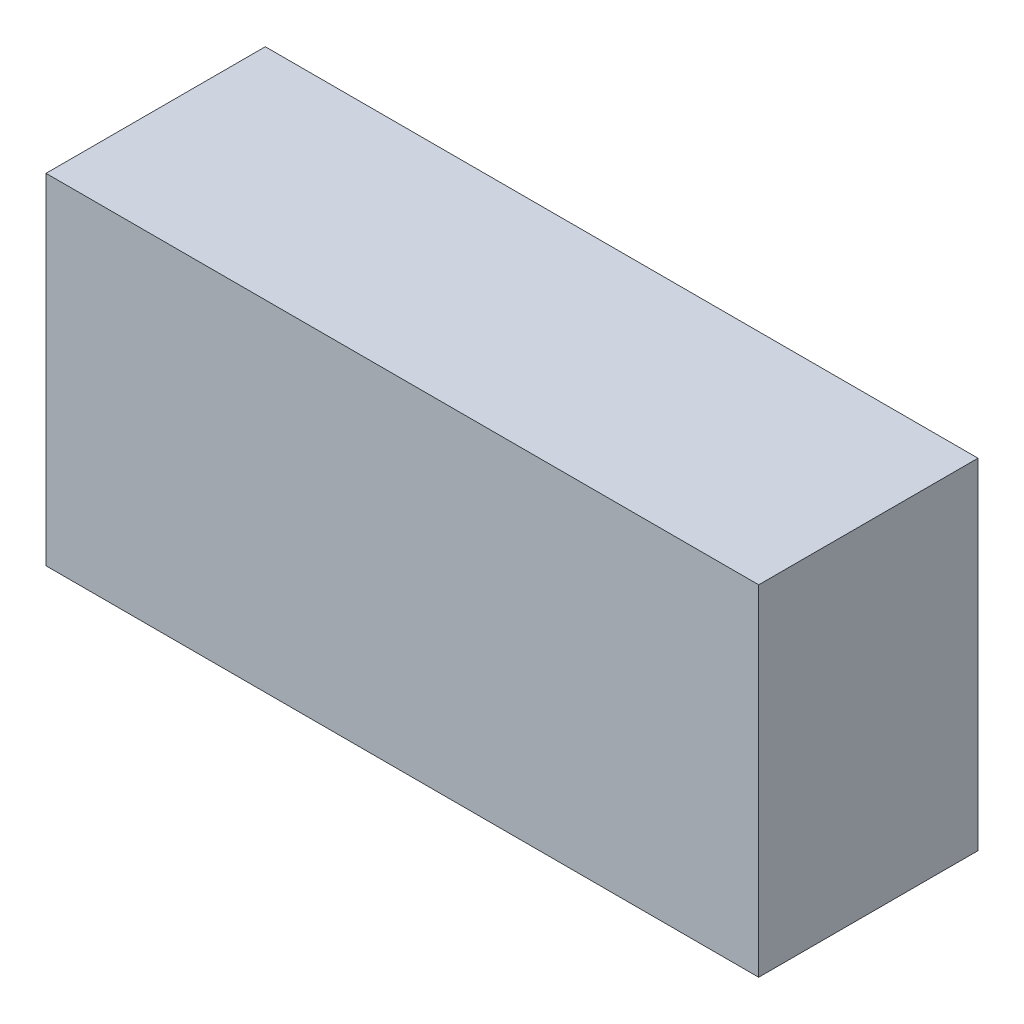
from build123d import *

# Parameters (mm, degrees)
SKETCH_1_W      = 19.5
SKETCH_1_H      = 6
EXTRUDE_1_DEPTH = 9.3
SKETCH_2_W      = 0.6
SKETCH_2_H      = 0.3
EXTRUDE_2_DEPTH = 3
EXTRUDE_3_DEPTH = 0.2


with BuildPart() as part:
    # Эскиз1 → Бобышка-Вытянуть1 (new body)
    with BuildSketch(Plane(origin=(0, 0, 0), x_dir=(1, 0, 0), z_dir=(0, 1, 0))):
        Rectangle(SKETCH_1_W, SKETCH_1_H)
    extrude(amount=EXTRUDE_1_DEPTH)

    # Эскиз2 → Бобышка-Вытянуть2 (add)
    with BuildSketch(Plane.XZ):
        with Locations((-7.62, -1.35)):
            Rectangle(SKETCH_2_W, SKETCH_2_H)
        with Locations((-5.08, -1.35)):
            Rectangle(SKETCH_2_W, SKETCH_2_H)
        with Locations((0, -1.35)):
            Rectangle(SKETCH_2_W, SKETCH_2_H)
        with Locations((2.54, -1.35)):
            Rectangle(SKETCH_2_W, SKETCH_2_H)
        with Locations((5.08, -1.35)):
            Rectangle(SKETCH_2_W, SKETCH_2_H)
    extrude(amount=EXTRUDE_2_DEPTH)

    # Эскиз3 → Бобышка-Вытянуть3 (add)
    with BuildSketch(Plane(origin=(0, 9.3, 0), x_dir=(1, 0, 0), z_dir=(0, 1, 0))):
        with BuildLine():
            Line((-5.993653669, -1.1506083), (-5.993653669, 1.495225034))
            Line((-5.993653669, 1.495225034), (-5.726526265, 1.495225034))
            add(Edge.make_bspline(
                [(-5.726526265, 1.495225034), (-5.703199399, 1.494894605), (-5.65827213, 1.494258204), (-5.593328368, 1.490121291), (-5.533294043, 1.482863062), (-5.478257825, 1.472268509), (-5.427978548, 1.459234752), (-5.382722262, 1.442777118), (-5.342163377, 1.423550544), (-5.318249105, 1.407525081), (-5.30675463, 1.39982239)],
                knots=[0, 0, 0, 0, 6.998e-05, 0.000134781, 0.00019513, 0.000251262, 0.000302815, 0.000350769, 0.00039557, 0.000437033, 0.000437033, 0.000437033, 0.000437033], degree=3))
            add(Edge.make_bspline(
                [(-5.30675463, 1.39982239), (-5.291259723, 1.387980041), (-5.259666671, 1.363834307), (-5.216878942, 1.320049614), (-5.176018095, 1.270953839), (-5.138198125, 1.215037198), (-5.103093917, 1.153229673), (-5.069860634, 1.085379539), (-5.040008142, 1.011214307), (-5.012613306, 0.931196499), (-4.987736933, 0.846373762), (-4.966676113, 0.756972928), (-4.948733764, 0.663775398), (-4.933891633, 0.566532567), (-4.922334069, 0.465223791), (-4.913792213, 0.359881256), (-4.909099881, 0.250617555), (-4.908492313, 0.176552723), (-4.908183583, 0.138917442)],
                knots=[0, 0, 0, 0, 5.8439e-05, 0.000119153, 0.000183146, 0.000249888, 0.000321348, 0.000396253, 0.000476369, 0.000561014, 0.000649908, 0.00074144, 0.000836447, 0.000934568, 0.00103647, 0.001142284, 0.001251571, 0.001364475, 0.001364475, 0.001364475, 0.001364475], degree=3))
            add(Edge.make_bspline(
                [(-4.908183583, 0.138917442), (-4.908280711, 0.106227192), (-4.908471905, 0.041877192), (-4.913150802, -0.053011126), (-4.919308515, -0.144931602), (-4.928055359, -0.233911091), (-4.940620124, -0.319900369), (-4.954621979, -0.403063397), (-4.971578805, -0.483169429), (-4.991199381, -0.559859585), (-5.012673437, -0.632560972), (-5.036144523, -0.700772196), (-5.060756945, -0.763964681), (-5.08687661, -0.822459494), (-5.11469083, -0.875845291), (-5.14459931, -0.924137506), (-5.175194817, -0.968146848), (-5.208238178, -1.00695942), (-5.243405122, -1.041684613), (-5.282312993, -1.070675465), (-5.324207669, -1.095483025), (-5.369598006, -1.115586755), (-5.418401512, -1.131573487), (-5.470683253, -1.142394162), (-5.525977989, -1.149628644), (-5.56396405, -1.150276458), (-5.583422299, -1.1506083)],
                knots=[0, 0, 0, 0, 9.8058e-05, 0.000193026, 0.000284939, 0.000374436, 0.000461159, 0.000545593, 0.000627403, 0.000706717, 0.000783019, 0.000854758, 0.000923064, 0.000986404, 0.001046858, 0.001103491, 0.001156725, 0.001207487, 0.001256214, 0.001304658, 0.001352653, 0.001402001, 0.001453289, 0.00150641, 0.00156196, 0.0016203, 0.0016203, 0.0016203, 0.0016203], degree=3))
            Line((-5.583422299, -1.1506083), (-5.993653669, -1.1506083))
        make_face()
        with BuildLine():
            Line((-5.857969908, -0.879240778), (-5.712215868, -0.879240778))
            add(Edge.make_bspline(
                [(-5.712215868, -0.879240778), (-5.691187559, -0.879056917), (-5.650871591, -0.878704415), (-5.592868926, -0.875504605), (-5.539970165, -0.870356677), (-5.491975474, -0.863079212), (-5.449019914, -0.853425769), (-5.410665043, -0.842750873), (-5.377422356, -0.829210676), (-5.358215906, -0.817468128), (-5.349155806, -0.811928913)],
                knots=[0, 0, 0, 0, 6.3081e-05, 0.00012094, 0.000174206, 0.000222481, 0.000266459, 0.00030621, 0.000341843, 0.000373662, 0.000373662, 0.000373662, 0.000373662], degree=3))
            add(Edge.make_bspline(
                [(-5.349155806, -0.811928913), (-5.337504042, -0.803307558), (-5.313789347, -0.785760618), (-5.280583663, -0.754767955), (-5.250258232, -0.718316423), (-5.220506136, -0.67810954), (-5.194552767, -0.631854361), (-5.168983681, -0.581836894), (-5.145554456, -0.526783834), (-5.124665533, -0.467032902), (-5.105604787, -0.403212154), (-5.089398291, -0.335730556), (-5.074936985, -0.265071796), (-5.063189934, -0.190820741), (-5.055092671, -0.112940991), (-5.048787041, -0.03182255), (-5.044151944, 0.052648833), (-5.043963526, 0.110113423), (-5.043867344, 0.139447456)],
                knots=[0, 0, 0, 0, 4.3464e-05, 8.8463e-05, 0.000135833, 0.000185556, 0.000238281, 0.000294694, 0.000354058, 0.000417592, 0.000484502, 0.00055379, 0.00062572, 0.000700832, 0.000779205, 0.000860546, 0.000944925, 0.001032914, 0.001032914, 0.001032914, 0.001032914], degree=3))
            add(Edge.make_bspline(
                [(-5.043867344, 0.139447456), (-5.044257686, 0.170367783), (-5.045023027, 0.230993015), (-5.04851762, 0.320105791), (-5.055303295, 0.405703496), (-5.065721936, 0.487818585), (-5.0773982, 0.566813362), (-5.093024206, 0.642256147), (-5.110894459, 0.714268364), (-5.131375406, 0.782633857), (-5.154756204, 0.846351158), (-5.179273421, 0.905648959), (-5.207154577, 0.959280213), (-5.236388534, 1.0081843), (-5.26864597, 1.051395115), (-5.302252635, 1.09000415), (-5.339137971, 1.122477508), (-5.365409332, 1.140706418), (-5.378306614, 1.149655456)],
                knots=[0, 0, 0, 0, 9.2766e-05, 0.000181886, 0.000267496, 0.000350263, 0.000430171, 0.000506986, 0.000581287, 0.000652715, 0.000720955, 0.000784843, 0.000845053, 0.000902138, 0.000955564, 0.001006622, 0.001055435, 0.001102508, 0.001102508, 0.001102508, 0.001102508], degree=3))
            add(Edge.make_bspline(
                [(-5.378306614, 1.149655456), (-5.388955984, 1.155743208), (-5.411039459, 1.168367307), (-5.448391882, 1.183007997), (-5.490098558, 1.195464632), (-5.536608314, 1.206268717), (-5.588034553, 1.213841748), (-5.644095768, 1.219565094), (-5.704918011, 1.223470072), (-5.747013657, 1.223724871), (-5.76892744, 1.223857512)],
                knots=[0, 0, 0, 0, 3.6759e-05, 7.6226e-05, 0.000119987, 0.000167301, 0.000219323, 0.000275807, 0.000336342, 0.000402072, 0.000402072, 0.000402072, 0.000402072], degree=3))
            Line((-5.76892744, 1.223857512), (-5.857969908, 1.223857512))
            Line((-5.857969908, 1.223857512), (-5.857969908, -0.879240778))
        make_face(mode=Mode.SUBTRACT)
        with BuildLine():
            Line((-3.415662216, 1.009731578), (-3.519545095, 0.850727171))
            add(Edge.make_bspline(
                [(-3.519545095, 0.850727171), (-3.534179354, 0.884905992), (-3.562170932, 0.950281296), (-3.611133312, 1.040000729), (-3.665533305, 1.116106536), (-3.72384652, 1.179351808), (-3.785927203, 1.2295169), (-3.851769423, 1.265264449), (-3.920886372, 1.287938638), (-3.968476618, 1.290444177), (-3.992318199, 1.291699393)],
                knots=[0, 0, 0, 0, 0.000111505, 0.00021328, 0.000305946, 0.000391448, 0.000470663, 0.000544181, 0.000615258, 0.000686614, 0.000686614, 0.000686614, 0.000686614], degree=3))
            add(Edge.make_bspline(
                [(-3.992318199, 1.291699393), (-4.005431836, 1.291384283), (-4.03169845, 1.290753119), (-4.070396571, 1.282732829), (-4.108512905, 1.271147784), (-4.145817601, 1.254474313), (-4.182279862, 1.233158987), (-4.218304257, 1.207461497), (-4.252957775, 1.176608367), (-4.299075833, 1.128977162), (-4.352642098, 1.059690199), (-4.408114943, 0.964195578), (-4.457114694, 0.856544197), (-4.497127403, 0.73650285), (-4.529213424, 0.606387938), (-4.552370998, 0.467849217), (-4.566279092, 0.321350851), (-4.568060213, 0.221100812), (-4.568974182, 0.169658294)],
                knots=[0, 0, 0, 0, 3.9278e-05, 7.8675e-05, 0.000118071, 0.000158647, 0.000200919, 0.000244603, 0.000291171, 0.000339898, 0.000443375, 0.000552908, 0.000670553, 0.000797599, 0.000931932, 0.001072217, 0.001218621, 0.001372929, 0.001372929, 0.001372929, 0.001372929], degree=3))
            add(Edge.make_bspline(
                [(-4.568974182, 0.169658294), (-4.568505048, 0.130597956), (-4.567586992, 0.054160166), (-4.559240598, -0.057952809), (-4.546936059, -0.165048085), (-4.528789063, -0.267326934), (-4.505707102, -0.364750482), (-4.477047103, -0.45737923), (-4.443102256, -0.544809514), (-4.404897438, -0.626691155), (-4.362284373, -0.700931952), (-4.317155352, -0.766581502), (-4.268464955, -0.821815298), (-4.217519197, -0.867484278), (-4.163381985, -0.903364651), (-4.106076555, -0.928124148), (-4.046251249, -0.944766536), (-4.0051504, -0.946304829), (-3.984367978, -0.947082659)],
                knots=[0, 0, 0, 0, 0.000117163, 0.000229279, 0.000337095, 0.000440441, 0.000540713, 0.000637275, 0.000731075, 0.000821883, 0.000908068, 0.000987615, 0.00106046, 0.00112842, 0.001192368, 0.001254309, 0.001315115, 0.00137731, 0.00137731, 0.00137731, 0.00137731], degree=3))
            add(Edge.make_bspline(
                [(-3.984367978, -0.947082659), (-3.961591638, -0.945772388), (-3.91597232, -0.943148013), (-3.849479838, -0.921072886), (-3.786097826, -0.886024876), (-3.72623861, -0.836482885), (-3.669438198, -0.773568722), (-3.615488809, -0.697122197), (-3.564594685, -0.606919476), (-3.53506219, -0.540833581), (-3.519545095, -0.506110436)],
                knots=[0, 0, 0, 0, 6.8191e-05, 0.000136581, 0.000207984, 0.00028447, 0.000368503, 0.0004616, 0.000564616, 0.000678669, 0.000678669, 0.000678669, 0.000678669], degree=3))
            Line((-3.519545095, -0.506110436), (-3.415662216, -0.663524799))
            add(Edge.make_bspline(
                [(-3.415662216, -0.663524799), (-3.423957596, -0.684978718), (-3.440269776, -0.727166079), (-3.467335967, -0.787728881), (-3.495194986, -0.84501035), (-3.525867748, -0.89780762), (-3.556548419, -0.947988701), (-3.590310996, -0.993379854), (-3.624691432, -1.035567179), (-3.660650472, -1.073847065), (-3.698141543, -1.107588466), (-3.736619231, -1.137280461), (-3.77637805, -1.161955477), (-3.816885086, -1.183164813), (-3.85890478, -1.199070077), (-3.902132842, -1.210062204), (-3.946310126, -1.217400972), (-3.976211705, -1.218098955), (-3.991258169, -1.21845018)],
                knots=[0, 0, 0, 0, 6.8994e-05, 0.00013567, 0.000198958, 0.000259965, 0.000318787, 0.00037529, 0.000429512, 0.000482002, 0.000532665, 0.000580686, 0.000627598, 0.000672873, 0.000717662, 0.000762012, 0.00080654, 0.000851641, 0.000851641, 0.000851641, 0.000851641], degree=3))
            add(Edge.make_bspline(
                [(-3.991258169, -1.21845018), (-4.019498028, -1.217044905), (-4.0752501, -1.214270565), (-4.156243448, -1.191380627), (-4.232478086, -1.154894405), (-4.303933806, -1.103497233), (-4.369809131, -1.03705277), (-4.431329731, -0.956814193), (-4.488334905, -0.862118671), (-4.520381829, -0.792319622), (-4.5371733, -0.755747355)],
                knots=[0, 0, 0, 0, 8.4598e-05, 0.000167017, 0.000250464, 0.000337091, 0.000429662, 0.000530164, 0.000639786, 0.000760445, 0.000760445, 0.000760445, 0.000760445], degree=3))
            add(Edge.make_bspline(
                [(-4.5371733, -0.755747355), (-4.550705935, -0.722524172), (-4.578175766, -0.655084593), (-4.611354565, -0.549272101), (-4.641067127, -0.438918067), (-4.663731428, -0.323171427), (-4.682780542, -0.202666631), (-4.694840811, -0.076988272), (-4.7032721, 0.053646598), (-4.704190154, 0.142436449), (-4.704657942, 0.187678793)],
                knots=[0, 0, 0, 0, 0.000107577, 0.000218371, 0.000332403, 0.000450276, 0.000572011, 0.000698267, 0.000828893, 0.000964602, 0.000964602, 0.000964602, 0.000964602], degree=3))
            add(Edge.make_bspline(
                [(-4.704657942, 0.187678793), (-4.704071921, 0.235219874), (-4.702922615, 0.328457448), (-4.693182896, 0.465378871), (-4.677450347, 0.596485968), (-4.655352591, 0.721825733), (-4.626464582, 0.841351733), (-4.592607123, 0.955511927), (-4.550817993, 1.063548764), (-4.503763829, 1.164964211), (-4.452114913, 1.257588782), (-4.39660512, 1.338869898), (-4.33732567, 1.407454084), (-4.27538001, 1.464439326), (-4.209548403, 1.508797556), (-4.140164332, 1.539888447), (-4.067577761, 1.559396918), (-4.017878723, 1.561837656), (-3.992848213, 1.563066914)],
                knots=[0, 0, 0, 0, 0.000142609, 0.000279686, 0.000411561, 0.00053861, 0.00066125, 0.000780297, 0.000895559, 0.001008427, 0.001115455, 0.00121337, 0.001303168, 0.001386845, 0.001465196, 0.00154016, 0.001614078, 0.00168908, 0.00168908, 0.00168908, 0.00168908], degree=3))
            add(Edge.make_bspline(
                [(-3.992848213, 1.563066914), (-3.977627939, 1.562703678), (-3.947380615, 1.561981816), (-3.902594067, 1.554813267), (-3.859097397, 1.543179618), (-3.816832763, 1.526858437), (-3.775181493, 1.507110913), (-3.73550092, 1.4809088), (-3.696205136, 1.451551931), (-3.658548924, 1.417201519), (-3.62206409, 1.379288724), (-3.587540342, 1.337134575), (-3.554988139, 1.291302038), (-3.522540397, 1.242799461), (-3.494096057, 1.189331801), (-3.46554633, 1.133068857), (-3.43918824, 1.072902791), (-3.423587095, 1.031011171), (-3.415662216, 1.009731578)],
                knots=[0, 0, 0, 0, 4.5631e-05, 9.0682e-05, 0.00013568, 0.000180469, 0.000226455, 0.00027365, 0.000322836, 0.000373499, 0.000426354, 0.000480576, 0.000536768, 0.000594983, 0.000655472, 0.000718285, 0.000784263, 0.000852377, 0.000852377, 0.000852377, 0.000852377], degree=3))
        make_face()
        with BuildLine():
            Line((-1.448247686, 1.009731578), (-1.552130565, 0.850727171))
            add(Edge.make_bspline(
                [(-1.552130565, 0.850727171), (-1.566764824, 0.884905992), (-1.594756402, 0.950281296), (-1.643718782, 1.040000729), (-1.698118775, 1.116106536), (-1.75643199, 1.179351808), (-1.818512673, 1.2295169), (-1.884354893, 1.265264449), (-1.953471842, 1.287938638), (-2.001062088, 1.290444177), (-2.024903669, 1.291699393)],
                knots=[0, 0, 0, 0, 0.000111505, 0.00021328, 0.000305946, 0.000391448, 0.000470663, 0.000544181, 0.000615258, 0.000686614, 0.000686614, 0.000686614, 0.000686614], degree=3))
            add(Edge.make_bspline(
                [(-2.024903669, 1.291699393), (-2.038017306, 1.291384283), (-2.06428392, 1.290753119), (-2.102982041, 1.282732829), (-2.141098375, 1.271147784), (-2.178403071, 1.254474313), (-2.214865332, 1.233158987), (-2.250889728, 1.207461497), (-2.285543246, 1.176608367), (-2.331661303, 1.128977162), (-2.385227568, 1.059690199), (-2.440700413, 0.964195578), (-2.489700164, 0.856544197), (-2.529712873, 0.73650285), (-2.561798894, 0.606387938), (-2.584956468, 0.467849217), (-2.598864562, 0.321350851), (-2.600645683, 0.221100812), (-2.601559652, 0.169658294)],
                knots=[0, 0, 0, 0, 3.9278e-05, 7.8675e-05, 0.000118071, 0.000158647, 0.000200919, 0.000244603, 0.000291171, 0.000339898, 0.000443375, 0.000552908, 0.000670553, 0.000797599, 0.000931932, 0.001072217, 0.001218621, 0.001372929, 0.001372929, 0.001372929, 0.001372929], degree=3))
            add(Edge.make_bspline(
                [(-2.601559652, 0.169658294), (-2.601090518, 0.130597956), (-2.600172462, 0.054160166), (-2.591826069, -0.057952809), (-2.579521529, -0.165048085), (-2.561374533, -0.267326934), (-2.538292572, -0.364750482), (-2.509632573, -0.45737923), (-2.475687726, -0.544809514), (-2.437482908, -0.626691155), (-2.394869843, -0.700931952), (-2.349740822, -0.766581502), (-2.301050425, -0.821815298), (-2.250104667, -0.867484278), (-2.195967455, -0.903364651), (-2.138662025, -0.928124148), (-2.078836719, -0.944766536), (-2.03773587, -0.946304829), (-2.016953448, -0.947082659)],
                knots=[0, 0, 0, 0, 0.000117163, 0.000229279, 0.000337095, 0.000440441, 0.000540713, 0.000637275, 0.000731075, 0.000821883, 0.000908068, 0.000987615, 0.00106046, 0.00112842, 0.001192368, 0.001254309, 0.001315115, 0.00137731, 0.00137731, 0.00137731, 0.00137731], degree=3))
            add(Edge.make_bspline(
                [(-2.016953448, -0.947082659), (-1.994177108, -0.945772388), (-1.94855779, -0.943148013), (-1.882065308, -0.921072886), (-1.818683296, -0.886024876), (-1.75882408, -0.836482885), (-1.702023668, -0.773568722), (-1.648074279, -0.697122197), (-1.597180155, -0.606919476), (-1.56764766, -0.540833581), (-1.552130565, -0.506110436)],
                knots=[0, 0, 0, 0, 6.8191e-05, 0.000136581, 0.000207984, 0.00028447, 0.000368503, 0.0004616, 0.000564616, 0.000678669, 0.000678669, 0.000678669, 0.000678669], degree=3))
            Line((-1.552130565, -0.506110436), (-1.448247686, -0.663524799))
            add(Edge.make_bspline(
                [(-1.448247686, -0.663524799), (-1.456543066, -0.684978718), (-1.472855246, -0.727166079), (-1.499921437, -0.787728881), (-1.527780456, -0.84501035), (-1.558453218, -0.89780762), (-1.589133889, -0.947988701), (-1.622896466, -0.993379854), (-1.657276903, -1.035567179), (-1.693235942, -1.073847065), (-1.730727013, -1.107588466), (-1.769204701, -1.137280461), (-1.80896352, -1.161955477), (-1.849470556, -1.183164813), (-1.89149025, -1.199070077), (-1.934718312, -1.210062204), (-1.978895596, -1.217400972), (-2.008797175, -1.218098955), (-2.023843639, -1.21845018)],
                knots=[0, 0, 0, 0, 6.8994e-05, 0.00013567, 0.000198958, 0.000259965, 0.000318787, 0.00037529, 0.000429512, 0.000482002, 0.000532665, 0.000580686, 0.000627598, 0.000672873, 0.000717662, 0.000762012, 0.00080654, 0.000851641, 0.000851641, 0.000851641, 0.000851641], degree=3))
            add(Edge.make_bspline(
                [(-2.023843639, -1.21845018), (-2.052083499, -1.217044905), (-2.10783557, -1.214270565), (-2.188828918, -1.191380627), (-2.265063556, -1.154894405), (-2.336519276, -1.103497233), (-2.402394601, -1.03705277), (-2.463915201, -0.956814193), (-2.520920375, -0.862118671), (-2.552967299, -0.792319622), (-2.56975877, -0.755747355)],
                knots=[0, 0, 0, 0, 8.4598e-05, 0.000167017, 0.000250464, 0.000337091, 0.000429662, 0.000530164, 0.000639786, 0.000760445, 0.000760445, 0.000760445, 0.000760445], degree=3))
            add(Edge.make_bspline(
                [(-2.56975877, -0.755747355), (-2.583291406, -0.722524172), (-2.610761236, -0.655084593), (-2.643940035, -0.549272101), (-2.673652597, -0.438918067), (-2.696316898, -0.323171427), (-2.715366012, -0.202666631), (-2.727426281, -0.076988272), (-2.73585757, 0.053646598), (-2.736775624, 0.142436449), (-2.737243412, 0.187678793)],
                knots=[0, 0, 0, 0, 0.000107577, 0.000218371, 0.000332403, 0.000450276, 0.000572011, 0.000698267, 0.000828893, 0.000964602, 0.000964602, 0.000964602, 0.000964602], degree=3))
            add(Edge.make_bspline(
                [(-2.737243412, 0.187678793), (-2.736657391, 0.235219874), (-2.735508085, 0.328457448), (-2.725768366, 0.465378871), (-2.710035817, 0.596485968), (-2.687938062, 0.721825733), (-2.659050052, 0.841351733), (-2.625192593, 0.955511927), (-2.583403463, 1.063548764), (-2.536349299, 1.164964211), (-2.484700383, 1.257588782), (-2.42919059, 1.338869898), (-2.36991114, 1.407454084), (-2.307965481, 1.464439326), (-2.242133873, 1.508797556), (-2.172749802, 1.539888447), (-2.100163231, 1.559396918), (-2.050464193, 1.561837656), (-2.025433684, 1.563066914)],
                knots=[0, 0, 0, 0, 0.000142609, 0.000279686, 0.000411561, 0.00053861, 0.00066125, 0.000780297, 0.000895559, 0.001008427, 0.001115455, 0.00121337, 0.001303168, 0.001386845, 0.001465196, 0.00154016, 0.001614078, 0.00168908, 0.00168908, 0.00168908, 0.00168908], degree=3))
            add(Edge.make_bspline(
                [(-2.025433684, 1.563066914), (-2.010213409, 1.562703678), (-1.979966085, 1.561981816), (-1.935179537, 1.554813267), (-1.891682868, 1.543179618), (-1.849418233, 1.526858437), (-1.807766963, 1.507110913), (-1.76808639, 1.4809088), (-1.728790606, 1.451551931), (-1.691134394, 1.417201519), (-1.65464956, 1.379288724), (-1.620125812, 1.337134575), (-1.587573609, 1.291302038), (-1.555125867, 1.242799461), (-1.526681527, 1.189331801), (-1.4981318, 1.133068857), (-1.47177371, 1.072902791), (-1.456172565, 1.031011171), (-1.448247686, 1.009731578)],
                knots=[0, 0, 0, 0, 4.5631e-05, 9.0682e-05, 0.00013568, 0.000180469, 0.000226455, 0.00027365, 0.000322836, 0.000373499, 0.000426354, 0.000480576, 0.000536768, 0.000594983, 0.000655472, 0.000718285, 0.000784263, 0.000852377, 0.000852377, 0.000852377, 0.000852377], degree=3))
        make_face()
        with BuildLine():
            add(Edge.make_bspline(
                [(-0.786259338, 0.81680623), (-0.768295824, 0.81600169), (-0.732566431, 0.81440146), (-0.680834558, 0.797931704), (-0.631820933, 0.772336496), (-0.584557205, 0.737517515), (-0.540776603, 0.69167794), (-0.499317995, 0.636359406), (-0.460000564, 0.571323038), (-0.437251962, 0.523403355), (-0.425319334, 0.498267402)],
                knots=[0, 0, 0, 0, 5.3744e-05, 0.000106896, 0.00016118, 0.000219166, 0.000282133, 0.000350611, 0.000426238, 0.000509673, 0.000509673, 0.000509673, 0.000509673], degree=3))
            add(Edge.make_bspline(
                [(-0.425319334, 0.498267402), (-0.414728297, 0.473668234), (-0.393285396, 0.423864093), (-0.367227345, 0.345950642), (-0.344949151, 0.264885756), (-0.326032015, 0.180605301), (-0.313037159, 0.092656107), (-0.301778331, 0.001715256), (-0.296325548, -0.092631811), (-0.295403832, -0.15664916), (-0.29493572, -0.189161652)],
                knots=[0, 0, 0, 0, 8.0318e-05, 0.000162614, 0.000246195, 0.000332485, 0.00042154, 0.00051279, 0.000607313, 0.000704858, 0.000704858, 0.000704858, 0.000704858], degree=3))
            add(Edge.make_bspline(
                [(-0.29493572, -0.189161652), (-0.295349578, -0.221853946), (-0.296164678, -0.286241839), (-0.302406615, -0.381280091), (-0.313947295, -0.473153634), (-0.328136117, -0.562148356), (-0.348363023, -0.647748537), (-0.37105115, -0.730502442), (-0.399616521, -0.809793204), (-0.431334519, -0.885135131), (-0.466002773, -0.954682557), (-0.504376532, -1.015419427), (-0.54439823, -1.067563046), (-0.587749138, -1.110045823), (-0.633497994, -1.143475031), (-0.68201447, -1.167387439), (-0.73332845, -1.181735338), (-0.768503084, -1.183591994), (-0.786259338, -1.18452924)],
                knots=[0, 0, 0, 0, 9.8076e-05, 0.000193161, 0.000285527, 0.000375798, 0.000463354, 0.000549262, 0.000633082, 0.000715969, 0.000794428, 0.000865891, 0.000931204, 0.000991173, 0.001047364, 0.001100461, 0.001152664, 0.00120588, 0.00120588, 0.00120588, 0.00120588], degree=3))
            add(Edge.make_bspline(
                [(-0.786259338, -1.18452924), (-0.804011064, -1.183573351), (-0.839347322, -1.181670576), (-0.890886446, -1.167497137), (-0.939563391, -1.143481638), (-0.985339642, -1.109901724), (-1.029169741, -1.067601137), (-1.069769751, -1.015582232), (-1.108089348, -0.954665248), (-1.142724365, -0.885122221), (-1.174700554, -0.80992249), (-1.202146645, -0.73027545), (-1.226196077, -0.647953081), (-1.244970492, -0.561981879), (-1.260604899, -0.473275738), (-1.270903559, -0.381222106), (-1.277484843, -0.286251606), (-1.278252974, -0.221857236), (-1.278642985, -0.189161652)],
                knots=[0, 0, 0, 0, 5.3216e-05, 0.00010593, 0.000159027, 0.000215219, 0.000275568, 0.000341209, 0.000412672, 0.000491131, 0.000574018, 0.000657661, 0.000743715, 0.000831155, 0.000921514, 0.001013817, 0.001108903, 0.001206978, 0.001206978, 0.001206978, 0.001206978], degree=3))
            add(Edge.make_bspline(
                [(-1.278642985, -0.189161652), (-1.278178442, -0.156824813), (-1.277261294, -0.092982179), (-1.271726731, 0.001172955), (-1.260822889, 0.092024459), (-1.246682351, 0.179421159), (-1.228663621, 0.263684197), (-1.206507249, 0.344591254), (-1.180178476, 0.422410198), (-1.158834277, 0.472072399), (-1.148259371, 0.496677358)],
                knots=[0, 0, 0, 0, 9.7016e-05, 0.000191538, 0.000282789, 0.000371404, 0.000457064, 0.000541156, 0.00062295, 0.000703268, 0.000703268, 0.000703268, 0.000703268], degree=3))
            add(Edge.make_bspline(
                [(-1.148259371, 0.496677358), (-1.136349283, 0.522002036), (-1.113704774, 0.570151549), (-1.074129905, 0.635502295), (-1.032470577, 0.691022688), (-0.988335287, 0.736710879), (-0.941784971, 0.772713123), (-0.892146266, 0.797870409), (-0.840124761, 0.814365676), (-0.804223805, 0.81599229), (-0.786259338, 0.81680623)],
                knots=[0, 0, 0, 0, 8.391e-05, 0.000159537, 0.000228758, 0.000291725, 0.000349604, 0.000404359, 0.000458019, 0.000511763, 0.000511763, 0.000511763, 0.000511763], degree=3))
        make_face()
        with BuildLine():
            add(Edge.make_bspline(
                [(-0.786789353, 0.579359649), (-0.798886218, 0.578626652), (-0.82301766, 0.577164431), (-0.858223157, 0.565790098), (-0.891985195, 0.54813109), (-0.924214219, 0.522841727), (-0.955425443, 0.491122233), (-0.984444916, 0.45166165), (-1.012618435, 0.40574868), (-1.03916386, 0.353446946), (-1.063119203, 0.295895135), (-1.08500333, 0.23517698), (-1.103007324, 0.171409901), (-1.117135786, 0.10458493), (-1.128804156, 0.034930636), (-1.137341087, -0.03775207), (-1.142056769, -0.113305513), (-1.142654463, -0.164597934), (-1.142959224, -0.190751696)],
                knots=[0, 0, 0, 0, 3.6231e-05, 7.2276e-05, 0.000109971, 0.000150042, 0.000194642, 0.000243086, 0.000296628, 0.000356124, 0.000418829, 0.000483539, 0.000549644, 0.000617424, 0.000688351, 0.000761457, 0.00083687, 0.000915328, 0.000915328, 0.000915328, 0.000915328], degree=3))
            add(Edge.make_bspline(
                [(-1.142959224, -0.190751696), (-1.142326427, -0.224516359), (-1.141078433, -0.291106612), (-1.131865071, -0.389182871), (-1.117149789, -0.483748531), (-1.096763284, -0.57357852), (-1.071413696, -0.656915723), (-1.040686032, -0.730903139), (-1.007123923, -0.795724965), (-0.968484024, -0.849369276), (-0.926864889, -0.892616434), (-0.88217378, -0.923391467), (-0.835469388, -0.943959249), (-0.80288704, -0.946049798), (-0.786789353, -0.947082659)],
                knots=[0, 0, 0, 0, 0.000101283, 0.000199749, 0.000295251, 0.000388211, 0.000475888, 0.000556206, 0.000628288, 0.000694338, 0.000753929, 0.000807295, 0.000856506, 0.000904562, 0.000904562, 0.000904562, 0.000904562], degree=3))
            add(Edge.make_bspline(
                [(-0.786789353, -0.947082659), (-0.77069017, -0.946051352), (-0.738104797, -0.943963948), (-0.691424169, -0.923371461), (-0.646733496, -0.892772774), (-0.605620341, -0.849183125), (-0.567073213, -0.795601378), (-0.532659256, -0.731179148), (-0.50286572, -0.656761062), (-0.477438741, -0.573529964), (-0.456264431, -0.483823389), (-0.441761172, -0.389172967), (-0.432487835, -0.291109204), (-0.431248093, -0.224517231), (-0.430619481, -0.190751696)],
                knots=[0, 0, 0, 0, 4.8056e-05, 9.7268e-05, 0.000150634, 0.000209853, 0.000275903, 0.000348236, 0.000428353, 0.00051603, 0.000609109, 0.000704611, 0.000803077, 0.00090436, 0.00090436, 0.00090436, 0.00090436], degree=3))
            add(Edge.make_bspline(
                [(-0.430619481, -0.190751696), (-0.430925486, -0.16459819), (-0.431525619, -0.11330627), (-0.43622373, -0.037749215), (-0.444824287, 0.034920411), (-0.456272696, 0.104658662), (-0.471208982, 0.171356384), (-0.489265037, 0.235049505), (-0.51018443, 0.296139923), (-0.535093194, 0.353316751), (-0.561497144, 0.405725377), (-0.589562433, 0.451883468), (-0.619282428, 0.490756408), (-0.649875101, 0.523027156), (-0.68215154, 0.548104718), (-0.715878749, 0.56579737), (-0.750923549, 0.577105458), (-0.774871983, 0.578610634), (-0.786789353, 0.579359649)],
                knots=[0, 0, 0, 0, 7.8458e-05, 0.000153871, 0.000226977, 0.000297904, 0.000365798, 0.000431903, 0.000496436, 0.00055935, 0.000618846, 0.000672388, 0.000721152, 0.000765382, 0.000805454, 0.000843148, 0.000879193, 0.000914897, 0.000914897, 0.000914897, 0.000914897], degree=3))
        make_face(mode=Mode.SUBTRACT)
        with BuildLine():
            Line((-0.057489139, 0.78288529), (0.078194622, 0.78288529))
            Line((0.078194622, 0.78288529), (0.078194622, 0.434135624))
            add(Edge.make_bspline(
                [(0.078194622, 0.434135624), (0.090473003, 0.465415577), (0.113637798, 0.524429355), (0.152949616, 0.604831872), (0.194834574, 0.671538016), (0.238889072, 0.724881992), (0.285305471, 0.765981762), (0.333906321, 0.795133405), (0.385061357, 0.813338806), (0.420090417, 0.815653081), (0.437544582, 0.81680623)],
                knots=[0, 0, 0, 0, 0.000100786, 0.000190147, 0.000268074, 0.000336546, 0.000397026, 0.00045311, 0.000505739, 0.000558007, 0.000558007, 0.000558007, 0.000558007], degree=3))
            add(Edge.make_bspline(
                [(0.437544582, 0.81680623), (0.455045862, 0.815427277), (0.490332639, 0.812646977), (0.541313346, 0.791060513), (0.58784322, 0.755227665), (0.630597175, 0.706886804), (0.668635136, 0.647182672), (0.702902382, 0.578089279), (0.729745898, 0.498723058), (0.748524014, 0.426327988), (0.761213854, 0.361580804), (0.768691001, 0.305613031), (0.775834597, 0.243267015), (0.780778935, 0.174469796), (0.78505622, 0.099200266), (0.788120457, 0.017386139), (0.790404417, -0.070778848), (0.790490142, -0.13174174), (0.790534365, -0.163190932)],
                knots=[0, 0, 0, 0, 5.2396e-05, 0.000105644, 0.000163203, 0.000227379, 0.000298237, 0.000375036, 0.000458179, 0.000549065, 0.000599271, 0.000656013, 0.000718406, 0.000787511, 0.000862893, 0.000944577, 0.001033115, 0.001127459, 0.001127459, 0.001127459, 0.001127459], degree=3))
            Line((0.790534365, -0.163190932), (0.790534365, -1.1506083))
            Line((0.790534365, -1.1506083), (0.654850605, -1.1506083))
            Line((0.654850605, -1.1506083), (0.654850605, -0.241103091))
            add(Edge.make_bspline(
                [(0.654850605, -0.241103091), (0.654901746, -0.214778869), (0.654999567, -0.164426518), (0.654336012, -0.092345224), (0.653763884, -0.02697789), (0.653483685, 0.031507299), (0.65219473, 0.083088841), (0.651385129, 0.127800377), (0.649722976, 0.165603399), (0.648504281, 0.188562951), (0.647960414, 0.198809102)],
                knots=[0, 0, 0, 0, 7.8972e-05, 0.000151056, 0.00021625, 0.000275084, 0.000326506, 0.00037104, 0.000409234, 0.000440016, 0.000440016, 0.000440016, 0.000440016], degree=3))
            add(Edge.make_bspline(
                [(0.647960414, 0.198809102), (0.64571324, 0.228557571), (0.641486532, 0.28451144), (0.62687992, 0.362254523), (0.606153204, 0.428513347), (0.578600593, 0.482865252), (0.545764184, 0.526038935), (0.507034395, 0.556869493), (0.463086331, 0.576376873), (0.43173428, 0.578355115), (0.415813979, 0.579359649)],
                knots=[0, 0, 0, 0, 8.9445e-05, 0.000168238, 0.00023679, 0.000297, 0.000350226, 0.000398154, 0.000444225, 0.000491756, 0.000491756, 0.000491756, 0.000491756], degree=3))
            add(Edge.make_bspline(
                [(0.415813979, 0.579359649), (0.406406609, 0.579000598), (0.387683893, 0.578286007), (0.360081539, 0.570938273), (0.33358275, 0.559116182), (0.307478381, 0.542965196), (0.283097594, 0.521327564), (0.258056496, 0.496442104), (0.235236892, 0.465799284), (0.204330303, 0.41932629), (0.17016809, 0.353300208), (0.137666461, 0.265797944), (0.111887842, 0.169787872), (0.101560782, 0.102299758), (0.096215121, 0.067365458)],
                knots=[0, 0, 0, 0, 2.8171e-05, 5.6066e-05, 8.5018e-05, 0.000115019, 0.00014773, 0.000182586, 0.000220751, 0.000262058, 0.000350012, 0.000442939, 0.000541675, 0.000647632, 0.000647632, 0.000647632, 0.000647632], degree=3))
            add(Edge.make_bspline(
                [(0.096215121, 0.067365458), (0.094722013, 0.054299406), (0.091458026, 0.02573656), (0.088018321, -0.020765347), (0.084618429, -0.074640369), (0.082974455, -0.135808744), (0.080627648, -0.204343685), (0.078962715, -0.280139749), (0.078777293, -0.363360428), (0.078394295, -0.421308327), (0.078194622, -0.451518923)],
                knots=[0, 0, 0, 0, 3.945e-05, 8.6238e-05, 0.000139864, 0.000201382, 0.000269787, 0.000345596, 0.00042881, 0.000519444, 0.000519444, 0.000519444, 0.000519444], degree=3))
            Line((0.078194622, -0.451518923), (0.078194622, -1.1506083))
            Line((0.078194622, -1.1506083), (-0.057489139, -1.1506083))
            Line((-0.057489139, -1.1506083), (-0.057489139, 0.78288529))
        make_face()
        Polygon((0.960139066, 0.78288529), (1.109073194, 0.78288529), (1.418071759, -0.572362273), (1.727070323, 0.78288529), (1.876004451, 0.78288529), (1.435032229, -1.1506083), (1.401111288, -1.1506083), align=None)
        with BuildLine():
            Line((2.889922553, -0.540031376), (2.995395476, -0.650804447))
            add(Edge.make_bspline(
                [(2.995395476, -0.650804447), (2.986843686, -0.680395232), (2.970487553, -0.736990493), (2.942521837, -0.817003839), (2.912057191, -0.887868362), (2.879457332, -0.949958174), (2.845538594, -1.004400122), (2.808633959, -1.051024034), (2.770596064, -1.092025781), (2.729664271, -1.125657126), (2.686351339, -1.152060238), (2.640309908, -1.171116269), (2.591364043, -1.182420247), (2.557661232, -1.183821614), (2.540642872, -1.18452924)],
                knots=[0, 0, 0, 0, 9.2394e-05, 0.000176713, 0.000254103, 0.000323567, 0.000386941, 0.00044621, 0.000501698, 0.000554428, 0.000604603, 0.000653324, 0.00070334, 0.000754356, 0.000754356, 0.000754356, 0.000754356], degree=3))
            add(Edge.make_bspline(
                [(2.540642872, -1.18452924), (2.521647414, -1.183640859), (2.484157345, -1.181887521), (2.429827944, -1.167040394), (2.379028756, -1.142547769), (2.331434963, -1.108631038), (2.287208639, -1.064982098), (2.246363966, -1.011876656), (2.208773445, -0.949358119), (2.175199734, -0.878407616), (2.14487345, -0.80181485), (2.118547256, -0.721543549), (2.095394935, -0.638913847), (2.077792903, -0.553454635), (2.063477122, -0.465928955), (2.052550216, -0.375963316), (2.046997499, -0.283399275), (2.046075144, -0.220792035), (2.045609152, -0.189161652)],
                knots=[0, 0, 0, 0, 5.6912e-05, 0.000112323, 0.000167559, 0.000225353, 0.000286821, 0.000353295, 0.000425831, 0.000505245, 0.00058851, 0.000672815, 0.000758581, 0.000845796, 0.000934411, 0.001024609, 0.001117544, 0.001212441, 0.001212441, 0.001212441, 0.001212441], degree=3))
            add(Edge.make_bspline(
                [(2.045609152, -0.189161652), (2.045873668, -0.15947328), (2.04639684, -0.100754205), (2.051786754, -0.01391278), (2.060890014, 0.070583535), (2.073022901, 0.152637188), (2.088213979, 0.232307843), (2.107431802, 0.309412503), (2.130019131, 0.384099099), (2.148006457, 0.4324547), (2.156912237, 0.456396241)],
                knots=[0, 0, 0, 0, 8.9057e-05, 0.000176141, 0.000260893, 0.000343945, 0.000424919, 0.000504105, 0.000582235, 0.000658852, 0.000658852, 0.000658852, 0.000658852], degree=3))
            add(Edge.make_bspline(
                [(2.156912237, 0.456396241), (2.168632995, 0.484695311), (2.191034257, 0.538781819), (2.230346554, 0.612710631), (2.273772183, 0.674835599), (2.319012731, 0.726769821), (2.368669983, 0.766678288), (2.420853593, 0.796196308), (2.477065364, 0.813266793), (2.515446352, 0.815619232), (2.534812711, 0.81680623)],
                knots=[0, 0, 0, 0, 9.1865e-05, 0.000175578, 0.000250565, 0.000318877, 0.000381455, 0.00044076, 0.00049777, 0.000555835, 0.000555835, 0.000555835, 0.000555835], degree=3))
            add(Edge.make_bspline(
                [(2.534812711, 0.81680623), (2.554748952, 0.815766124), (2.594405397, 0.813697184), (2.65183856, 0.794307188), (2.706052042, 0.764148707), (2.757036124, 0.721954325), (2.803761609, 0.667157498), (2.84741589, 0.600847797), (2.889054115, 0.523315753), (2.911878401, 0.466198207), (2.923843493, 0.436255683)],
                knots=[0, 0, 0, 0, 5.9647e-05, 0.000118648, 0.000179857, 0.000245006, 0.000316006, 0.000395092, 0.000482825, 0.000579493, 0.000579493, 0.000579493, 0.000579493], degree=3))
            add(Edge.make_bspline(
                [(2.923843493, 0.436255683), (2.932239182, 0.413201379), (2.949323145, 0.366289341), (2.97040868, 0.292615183), (2.988276388, 0.214921509), (3.003065321, 0.133027608), (3.014880028, 0.047109802), (3.022341437, -0.043136194), (3.02798877, -0.137504611), (3.028867626, -0.201873), (3.029316417, -0.234742915)],
                knots=[0, 0, 0, 0, 7.3588e-05, 0.000149741, 0.00022971, 0.00031267, 0.000399321, 0.000489773, 0.000584265, 0.00068287, 0.00068287, 0.00068287, 0.00068287], degree=3))
            Line((3.029316417, -0.234742915), (2.181292912, -0.234742915))
            add(Edge.make_bspline(
                [(2.181292912, -0.234742915), (2.181678495, -0.260200358), (2.182434624, -0.310122463), (2.188977195, -0.383062876), (2.196139028, -0.452732985), (2.208276721, -0.518418832), (2.222091078, -0.580931888), (2.240558167, -0.639413961), (2.260293019, -0.695188709), (2.284027297, -0.746442985), (2.309787431, -0.793118227), (2.337226816, -0.833957866), (2.365822227, -0.868954932), (2.396201902, -0.897441422), (2.428280632, -0.919689367), (2.462240249, -0.935137296), (2.497484372, -0.945279826), (2.521671877, -0.946482143), (2.533752681, -0.947082659)],
                knots=[0, 0, 0, 0, 7.6352e-05, 0.000149726, 0.000219611, 0.000286359, 0.000350001, 0.000411531, 0.000470216, 0.000527372, 0.000580756, 0.000630002, 0.000674791, 0.000716043, 0.00075456, 0.000791319, 0.000827577, 0.000863758, 0.000863758, 0.000863758, 0.000863758], degree=3))
            add(Edge.make_bspline(
                [(2.533752681, -0.947082659), (2.545639735, -0.946606939), (2.569542184, -0.945650364), (2.604974005, -0.936674712), (2.639639986, -0.922120349), (2.67346179, -0.902275022), (2.70623002, -0.878366002), (2.735712001, -0.849147568), (2.763591626, -0.817379685), (2.789389289, -0.780548935), (2.813785808, -0.735605494), (2.838760192, -0.680839707), (2.864834398, -0.614459415), (2.881140963, -0.566083374), (2.889922553, -0.540031376)],
                knots=[0, 0, 0, 0, 3.561e-05, 7.1604e-05, 0.000108909, 0.000148091, 0.000189008, 0.00023024, 0.000272322, 0.0003157, 0.000364811, 0.00042552, 0.000496187, 0.000578655, 0.000578655, 0.000578655, 0.000578655], degree=3))
        make_face()
        with BuildLine():
            add(Edge.make_bspline(
                [(2.893632656, 0.002703666), (2.889284009, 0.034010969), (2.881026115, 0.093462193), (2.865510163, 0.177480153), (2.846565928, 0.2513368), (2.824740419, 0.316092891), (2.799611473, 0.373076112), (2.771085822, 0.423985739), (2.738043629, 0.468621467), (2.702141544, 0.507162291), (2.664626545, 0.539697143), (2.624200455, 0.561871031), (2.583241391, 0.577163797), (2.555082473, 0.57863361), (2.541172887, 0.579359649)],
                knots=[0, 0, 0, 0, 9.4819e-05, 0.000180058, 0.000256161, 0.000323372, 0.000384829, 0.000442746, 0.000498081, 0.000550958, 0.000600633, 0.000646192, 0.000688765, 0.000730323, 0.000730323, 0.000730323, 0.000730323], degree=3))
            add(Edge.make_bspline(
                [(2.541172887, 0.579359649), (2.529816757, 0.578884512), (2.507133469, 0.577935449), (2.47385806, 0.569147519), (2.442189002, 0.554200788), (2.410982235, 0.534723183), (2.382227004, 0.508241261), (2.354132644, 0.476873625), (2.327269582, 0.439956298), (2.31141713, 0.412390057), (2.303196291, 0.398094625)],
                knots=[0, 0, 0, 0, 3.4024e-05, 6.7962e-05, 0.000102352, 0.000138815, 0.000177856, 0.000219143, 0.000265047, 0.000314495, 0.000314495, 0.000314495, 0.000314495], degree=3))
            add(Edge.make_bspline(
                [(2.303196291, 0.398094625), (2.297196818, 0.386514034), (2.284674217, 0.362342057), (2.268605675, 0.323043588), (2.25313396, 0.279922048), (2.238820492, 0.232510016), (2.225838271, 0.18081587), (2.213491386, 0.125196651), (2.203104027, 0.065346625), (2.196768047, 0.02409169), (2.19348325, 0.002703666)],
                knots=[0, 0, 0, 0, 3.911e-05, 8.1633e-05, 0.000127233, 0.000176527, 0.000230132, 0.000287103, 0.000347404, 0.000412322, 0.000412322, 0.000412322, 0.000412322], degree=3))
            Line((2.19348325, 0.002703666), (2.893632656, 0.002703666))
        make_face(mode=Mode.SUBTRACT)
        with BuildLine():
            Line((3.232842058, 0.78288529), (3.368525818, 0.78288529))
            Line((3.368525818, 0.78288529), (3.368525818, 0.498267402))
            add(Edge.make_bspline(
                [(3.368525818, 0.498267402), (3.377158654, 0.524552332), (3.393329778, 0.573789553), (3.42143135, 0.640457161), (3.449280172, 0.695972089), (3.478235876, 0.740367655), (3.508981153, 0.773639524), (3.5391453, 0.798808716), (3.571522866, 0.813693408), (3.593653396, 0.815789862), (3.604382355, 0.81680623)],
                knots=[0, 0, 0, 0, 8.2969e-05, 0.000155418, 0.000216813, 0.000269145, 0.000313783, 0.000352274, 0.000386446, 0.000418603, 0.000418603, 0.000418603, 0.000418603], degree=3))
            add(Edge.make_bspline(
                [(3.604382355, 0.81680623), (3.612636765, 0.815852155), (3.63030099, 0.813810458), (3.656311976, 0.800158343), (3.682996722, 0.779137474), (3.699041042, 0.760599725), (3.70773522, 0.750554394)],
                knots=[0, 0, 0, 0, 2.4747e-05, 5.2957e-05, 8.6566e-05, 0.000126321, 0.000126321, 0.000126321, 0.000126321], degree=3))
            Line((3.70773522, 0.750554394), (3.642543413, 0.544908694))
            add(Edge.make_bspline(
                [(3.642543413, 0.544908694), (3.636790337, 0.549953037), (3.626169317, 0.559265631), (3.610540938, 0.570655945), (3.595769021, 0.577862983), (3.586068266, 0.578887071), (3.581591724, 0.579359649)],
                knots=[0, 0, 0, 0, 2.2938e-05, 4.2347e-05, 5.8007e-05, 7.1426e-05, 7.1426e-05, 7.1426e-05, 7.1426e-05], degree=3))
            add(Edge.make_bspline(
                [(3.581591724, 0.579359649), (3.571757888, 0.578001124), (3.550680791, 0.575089364), (3.522244285, 0.55270439), (3.494902966, 0.520205459), (3.467988632, 0.474936295), (3.443312282, 0.416541398), (3.422235918, 0.344225662), (3.403069108, 0.258414172), (3.39437154, 0.196066367), (3.389726406, 0.162768103)],
                knots=[0, 0, 0, 0, 2.9319e-05, 6.284e-05, 0.000104922, 0.000157007, 0.00021992, 0.000294699, 0.000382656, 0.000483477, 0.000483477, 0.000483477, 0.000483477], degree=3))
            add(Edge.make_bspline(
                [(3.389726406, 0.162768103), (3.388046347, 0.147406041), (3.38430524, 0.113198246), (3.380334433, 0.056444872), (3.376687708, -0.01087533), (3.37343455, -0.088612162), (3.371563998, -0.176789024), (3.369950645, -0.275372709), (3.368916238, -0.38455846), (3.368659912, -0.460882316), (3.368525818, -0.500810289)],
                knots=[0, 0, 0, 0, 4.6357e-05, 0.000103227, 0.000170641, 0.000248618, 0.000336626, 0.000435222, 0.00054441, 0.000664194, 0.000664194, 0.000664194, 0.000664194], degree=3))
            Line((3.368525818, -0.500810289), (3.368525818, -1.1506083))
            Line((3.368525818, -1.1506083), (3.232842058, -1.1506083))
            Line((3.232842058, -1.1506083), (3.232842058, 0.78288529))
        make_face()
        Polygon((3.911260861, 1.563066914), (4.046944622, 1.563066914), (4.046944622, 0.78288529), (4.216549323, 0.78288529), (4.216549323, 0.545438709), (4.046944622, 0.545438709), (4.046944622, -1.1506083), (3.911260861, -1.1506083), (3.911260861, 0.545438709), (3.74165616, 0.545438709), (3.74165616, 0.78288529), (3.911260861, 0.78288529), align=None)
        with BuildLine():
            Line((5.230467425, -0.540031376), (5.335940348, -0.650804447))
            add(Edge.make_bspline(
                [(5.335940348, -0.650804447), (5.327388558, -0.680395232), (5.311032425, -0.736990493), (5.283066708, -0.817003839), (5.252602063, -0.887868362), (5.220002204, -0.949958174), (5.186083466, -1.004400122), (5.149178831, -1.051024034), (5.111140936, -1.092025781), (5.070209142, -1.125657126), (5.026896211, -1.152060238), (4.98085478, -1.171116269), (4.931908915, -1.182420247), (4.898206104, -1.183821614), (4.881187744, -1.18452924)],
                knots=[0, 0, 0, 0, 9.2394e-05, 0.000176713, 0.000254103, 0.000323567, 0.000386941, 0.00044621, 0.000501698, 0.000554428, 0.000604603, 0.000653324, 0.00070334, 0.000754356, 0.000754356, 0.000754356, 0.000754356], degree=3))
            add(Edge.make_bspline(
                [(4.881187744, -1.18452924), (4.862192286, -1.183640859), (4.824702217, -1.181887521), (4.770372815, -1.167040394), (4.719573628, -1.142547769), (4.671979834, -1.108631038), (4.62775351, -1.064982098), (4.586908837, -1.011876656), (4.549318317, -0.949358119), (4.515744605, -0.878407616), (4.485418322, -0.80181485), (4.459092128, -0.721543549), (4.435939807, -0.638913847), (4.418337775, -0.553454635), (4.404021994, -0.465928955), (4.393095087, -0.375963316), (4.387542371, -0.283399275), (4.386620015, -0.220792035), (4.386154023, -0.189161652)],
                knots=[0, 0, 0, 0, 5.6912e-05, 0.000112323, 0.000167559, 0.000225353, 0.000286821, 0.000353295, 0.000425831, 0.000505245, 0.00058851, 0.000672815, 0.000758581, 0.000845796, 0.000934411, 0.001024609, 0.001117544, 0.001212441, 0.001212441, 0.001212441, 0.001212441], degree=3))
            add(Edge.make_bspline(
                [(4.386154023, -0.189161652), (4.38641854, -0.15947328), (4.386941712, -0.100754205), (4.392331626, -0.01391278), (4.401434885, 0.070583535), (4.413567773, 0.152637188), (4.428758851, 0.232307843), (4.447976673, 0.309412503), (4.470564003, 0.384099099), (4.488551329, 0.4324547), (4.497457108, 0.456396241)],
                knots=[0, 0, 0, 0, 8.9057e-05, 0.000176141, 0.000260893, 0.000343945, 0.000424919, 0.000504105, 0.000582235, 0.000658852, 0.000658852, 0.000658852, 0.000658852], degree=3))
            add(Edge.make_bspline(
                [(4.497457108, 0.456396241), (4.509177866, 0.484695311), (4.531579128, 0.538781819), (4.570891426, 0.612710631), (4.614317055, 0.674835599), (4.659557603, 0.726769821), (4.709214855, 0.766678288), (4.761398465, 0.796196308), (4.817610236, 0.813266793), (4.855991224, 0.815619232), (4.875357583, 0.81680623)],
                knots=[0, 0, 0, 0, 9.1865e-05, 0.000175578, 0.000250565, 0.000318877, 0.000381455, 0.00044076, 0.00049777, 0.000555835, 0.000555835, 0.000555835, 0.000555835], degree=3))
            add(Edge.make_bspline(
                [(4.875357583, 0.81680623), (4.895293824, 0.815766124), (4.934950269, 0.813697184), (4.992383432, 0.794307188), (5.046596914, 0.764148707), (5.097580996, 0.721954325), (5.144306481, 0.667157498), (5.187960762, 0.600847797), (5.229598987, 0.523315753), (5.252423273, 0.466198207), (5.264388365, 0.436255683)],
                knots=[0, 0, 0, 0, 5.9647e-05, 0.000118648, 0.000179857, 0.000245006, 0.000316006, 0.000395092, 0.000482825, 0.000579493, 0.000579493, 0.000579493, 0.000579493], degree=3))
            add(Edge.make_bspline(
                [(5.264388365, 0.436255683), (5.272784054, 0.413201379), (5.289868017, 0.366289341), (5.310953551, 0.292615183), (5.32882126, 0.214921509), (5.343610193, 0.133027608), (5.3554249, 0.047109802), (5.362886308, -0.043136194), (5.368533642, -0.137504611), (5.369412498, -0.201873), (5.369861288, -0.234742915)],
                knots=[0, 0, 0, 0, 7.3588e-05, 0.000149741, 0.00022971, 0.00031267, 0.000399321, 0.000489773, 0.000584265, 0.00068287, 0.00068287, 0.00068287, 0.00068287], degree=3))
            Line((5.369861288, -0.234742915), (4.521837784, -0.234742915))
            add(Edge.make_bspline(
                [(4.521837784, -0.234742915), (4.522223367, -0.260200358), (4.522979496, -0.310122463), (4.529522067, -0.383062876), (4.5366839, -0.452732985), (4.548821593, -0.518418832), (4.56263595, -0.580931888), (4.581103039, -0.639413961), (4.600837891, -0.695188709), (4.624572169, -0.746442985), (4.650332302, -0.793118227), (4.677771688, -0.833957866), (4.706367098, -0.868954932), (4.736746774, -0.897441422), (4.768825504, -0.919689367), (4.802785121, -0.935137296), (4.838029244, -0.945279826), (4.862216749, -0.946482143), (4.874297553, -0.947082659)],
                knots=[0, 0, 0, 0, 7.6352e-05, 0.000149726, 0.000219611, 0.000286359, 0.000350001, 0.000411531, 0.000470216, 0.000527372, 0.000580756, 0.000630002, 0.000674791, 0.000716043, 0.00075456, 0.000791319, 0.000827577, 0.000863758, 0.000863758, 0.000863758, 0.000863758], degree=3))
            add(Edge.make_bspline(
                [(4.874297553, -0.947082659), (4.886184606, -0.946606939), (4.910087056, -0.945650364), (4.945518877, -0.936674712), (4.980184858, -0.922120349), (5.014006662, -0.902275022), (5.046774892, -0.878366002), (5.076256872, -0.849147568), (5.104136498, -0.817379685), (5.129934161, -0.780548935), (5.154330679, -0.735605494), (5.179305064, -0.680839707), (5.20537927, -0.614459415), (5.221685835, -0.566083374), (5.230467425, -0.540031376)],
                knots=[0, 0, 0, 0, 3.561e-05, 7.1604e-05, 0.000108909, 0.000148091, 0.000189008, 0.00023024, 0.000272322, 0.0003157, 0.000364811, 0.00042552, 0.000496187, 0.000578655, 0.000578655, 0.000578655, 0.000578655], degree=3))
        make_face()
        with BuildLine():
            add(Edge.make_bspline(
                [(5.234177528, 0.002703666), (5.229828881, 0.034010969), (5.221570987, 0.093462193), (5.206055035, 0.177480153), (5.1871108, 0.2513368), (5.165285291, 0.316092891), (5.140156345, 0.373076112), (5.111630694, 0.423985739), (5.078588501, 0.468621467), (5.042686416, 0.507162291), (5.005171417, 0.539697143), (4.964745327, 0.561871031), (4.923786263, 0.577163797), (4.895627345, 0.57863361), (4.881717759, 0.579359649)],
                knots=[0, 0, 0, 0, 9.4819e-05, 0.000180058, 0.000256161, 0.000323372, 0.000384829, 0.000442746, 0.000498081, 0.000550958, 0.000600633, 0.000646192, 0.000688765, 0.000730323, 0.000730323, 0.000730323, 0.000730323], degree=3))
            add(Edge.make_bspline(
                [(4.881717759, 0.579359649), (4.870361629, 0.578884512), (4.84767834, 0.577935449), (4.814402932, 0.569147519), (4.782733873, 0.554200788), (4.751527107, 0.534723183), (4.722771876, 0.508241261), (4.694677516, 0.476873625), (4.667814453, 0.439956298), (4.651962002, 0.412390057), (4.643741163, 0.398094625)],
                knots=[0, 0, 0, 0, 3.4024e-05, 6.7962e-05, 0.000102352, 0.000138815, 0.000177856, 0.000219143, 0.000265047, 0.000314495, 0.000314495, 0.000314495, 0.000314495], degree=3))
            add(Edge.make_bspline(
                [(4.643741163, 0.398094625), (4.63774169, 0.386514034), (4.625219089, 0.362342057), (4.609150547, 0.323043588), (4.593678832, 0.279922048), (4.579365364, 0.232510016), (4.566383143, 0.18081587), (4.554036258, 0.125196651), (4.543648899, 0.065346625), (4.537312919, 0.02409169), (4.534028122, 0.002703666)],
                knots=[0, 0, 0, 0, 3.911e-05, 8.1633e-05, 0.000127233, 0.000176527, 0.000230132, 0.000287103, 0.000347404, 0.000412322, 0.000412322, 0.000412322, 0.000412322], degree=3))
            Line((4.534028122, 0.002703666), (5.234177528, 0.002703666))
        make_face(mode=Mode.SUBTRACT)
        with BuildLine():
            Line((5.573386929, 0.78288529), (5.70907069, 0.78288529))
            Line((5.70907069, 0.78288529), (5.70907069, 0.498267402))
            add(Edge.make_bspline(
                [(5.70907069, 0.498267402), (5.717703526, 0.524552332), (5.73387465, 0.573789553), (5.761976222, 0.640457161), (5.789825043, 0.695972089), (5.818780748, 0.740367655), (5.849526025, 0.773639524), (5.879690172, 0.798808716), (5.912067738, 0.813693408), (5.934198268, 0.815789862), (5.944927227, 0.81680623)],
                knots=[0, 0, 0, 0, 8.2969e-05, 0.000155418, 0.000216813, 0.000269145, 0.000313783, 0.000352274, 0.000386446, 0.000418603, 0.000418603, 0.000418603, 0.000418603], degree=3))
            add(Edge.make_bspline(
                [(5.944927227, 0.81680623), (5.953181637, 0.815852155), (5.970845861, 0.813810458), (5.996856848, 0.800158343), (6.023541594, 0.779137474), (6.039585914, 0.760599725), (6.048280092, 0.750554394)],
                knots=[0, 0, 0, 0, 2.4747e-05, 5.2957e-05, 8.6566e-05, 0.000126321, 0.000126321, 0.000126321, 0.000126321], degree=3))
            Line((6.048280092, 0.750554394), (5.983088285, 0.544908694))
            add(Edge.make_bspline(
                [(5.983088285, 0.544908694), (5.977335209, 0.549953037), (5.966714189, 0.559265631), (5.95108581, 0.570655945), (5.936313892, 0.577862983), (5.926613138, 0.578887071), (5.922136596, 0.579359649)],
                knots=[0, 0, 0, 0, 2.2938e-05, 4.2347e-05, 5.8007e-05, 7.1426e-05, 7.1426e-05, 7.1426e-05, 7.1426e-05], degree=3))
            add(Edge.make_bspline(
                [(5.922136596, 0.579359649), (5.912302759, 0.578001124), (5.891225663, 0.575089364), (5.862789157, 0.55270439), (5.835447838, 0.520205459), (5.808533504, 0.474936295), (5.783857153, 0.416541398), (5.76278079, 0.344225662), (5.743613979, 0.258414172), (5.734916412, 0.196066367), (5.730271278, 0.162768103)],
                knots=[0, 0, 0, 0, 2.9319e-05, 6.284e-05, 0.000104922, 0.000157007, 0.00021992, 0.000294699, 0.000382656, 0.000483477, 0.000483477, 0.000483477, 0.000483477], degree=3))
            add(Edge.make_bspline(
                [(5.730271278, 0.162768103), (5.728591219, 0.147406041), (5.724850112, 0.113198246), (5.720879305, 0.056444872), (5.71723258, -0.01087533), (5.713979422, -0.088612162), (5.712108869, -0.176789024), (5.710495517, -0.275372709), (5.70946111, -0.38455846), (5.709204784, -0.460882316), (5.70907069, -0.500810289)],
                knots=[0, 0, 0, 0, 4.6357e-05, 0.000103227, 0.000170641, 0.000248618, 0.000336626, 0.000435222, 0.00054441, 0.000664194, 0.000664194, 0.000664194, 0.000664194], degree=3))
            Line((5.70907069, -0.500810289), (5.70907069, -1.1506083))
            Line((5.70907069, -1.1506083), (5.573386929, -1.1506083))
            Line((5.573386929, -1.1506083), (5.573386929, 0.78288529))
        make_face()
    extrude(amount=-EXTRUDE_3_DEPTH)


solid = part.part
